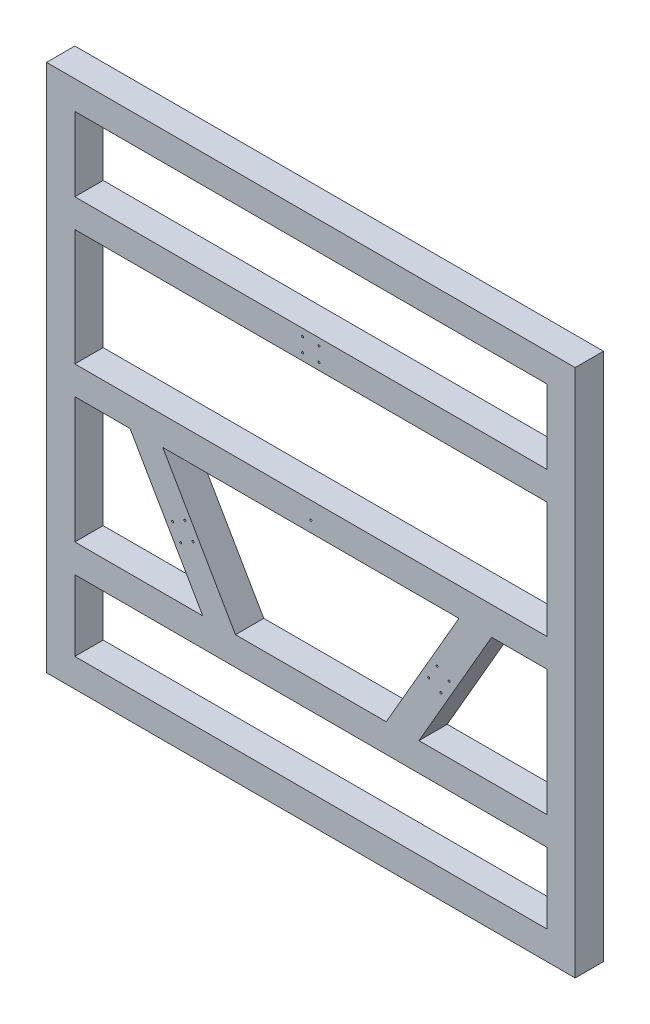
from build123d import *

# Parameters (mm, degrees)
CROQUIS1_W                   = 1680
CROQUIS1_H                   = 1680
CROQUIS1_W_2                 = 1500
CROQUIS1_H_2                 = 1500
CROQUIS1_H_3                 = 90
SALIENTE_EXTRUIR1_DEPTH      = 90
TALADRO_DE_MARGEN_PARA_M61_D = 6.4


with BuildPart() as part:
    # Croquis1 → Saliente-Extruir1 (new body)
    with BuildSketch(Plane.XY):
        Rectangle(CROQUIS1_W, CROQUIS1_H)
        Rectangle(CROQUIS1_W_2, CROQUIS1_H_2, mode=Mode.SUBTRACT)
        with Locations((0, 470)):
            Rectangle(CROQUIS1_W_2, CROQUIS1_H_3)
        Polygon((-750, 55), (-750, -35), (-574.463517844, -35), (-470.54046939, -35), (470.54046939, -35), (574.463517844, -35), (750, -35), (750, 55), align=None)
        Polygon((-750, -435), (-750, -525), (750, -525), (750, -435), (343.523410168, -435), (239.600361714, -435), (-239.600361714, -435), (-343.523410168, -435), align=None)
        Polygon((-574.463517844, -35), (-343.523410168, -435), (-239.600361714, -435), (-470.54046939, -35), align=None)
        Polygon((239.600361714, -435), (343.523410168, -435), (574.463517844, -35), (470.54046939, -35), align=None)
    extrude(amount=SALIENTE_EXTRUIR1_DEPTH)

    # Taladro de margen para M61 (through all)
    with Locations(Plane.XY.offset(90)):
        with Locations((-26, 492.5), (26, 492.5), (26, 447.5), (-26, 447.5), (439.517511364, -223.733339502), (413.517511364, -268.766660498), (374.546368194, -246.266660498), (400.546368194, -201.233339502), (-413.517511364, -268.766660498), (-439.517511364, -223.733339502), (-400.546368194, -201.233339502), (-374.546368194, -246.266660498), (0, 0)):
            Hole(TALADRO_DE_MARGEN_PARA_M61_D / 2)


solid = part.part
